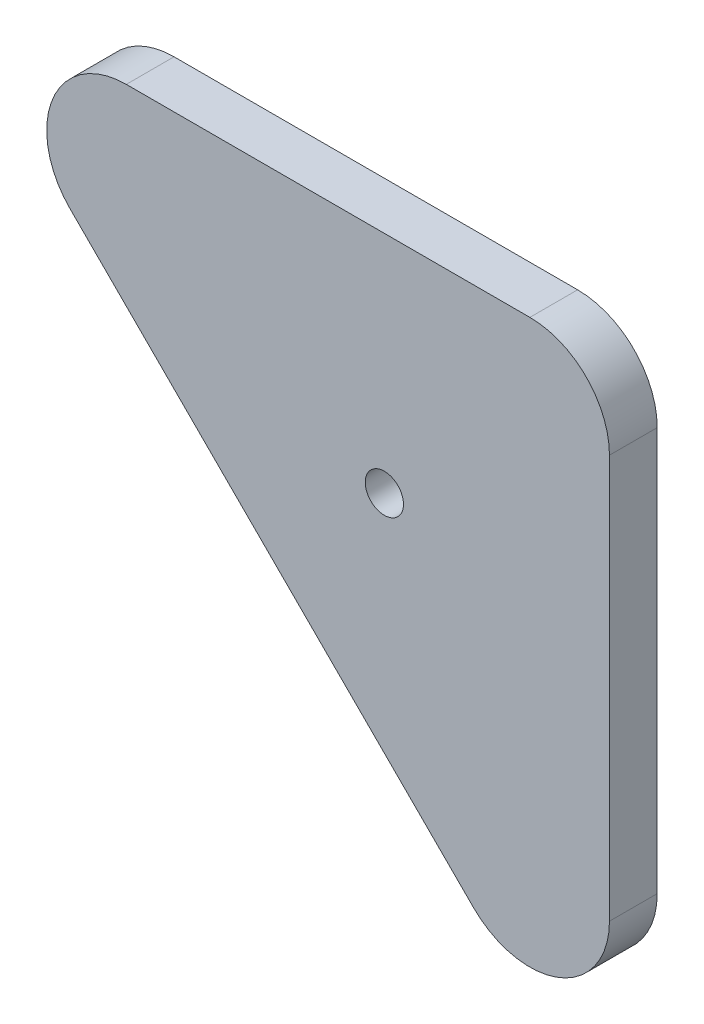
from build123d import *

# Parameters (mm, degrees)
SKETCH1_R           = 2.4
BOSS_EXTRUDE1_DEPTH = 6


with BuildPart() as part:
    # Sketch1 → Boss-Extrude1 (new body)
    with BuildSketch(Plane.XY):
        with BuildLine():
            Line((552.928932188, 502.218254069), (502.218254069, 552.928932188))
            ThreePointArc((502.218254069, 552.928932188), (500.050526556, 563.826834324), (509.289321881, 570))
            Line((509.289321881, 570), (560, 570))
            ThreePointArc((560, 570), (567.071067812, 567.071067812), (570, 560))
            Line((570, 560), (570, 509.289321881))
            ThreePointArc((570, 509.289321881), (563.826834324, 500.050526556), (552.928932188, 502.218254069))
        make_face()
        with Locations((541.715728753, 541.715728753)):
            Circle(SKETCH1_R, mode=Mode.SUBTRACT)
    extrude(amount=BOSS_EXTRUDE1_DEPTH)


solid = part.part
